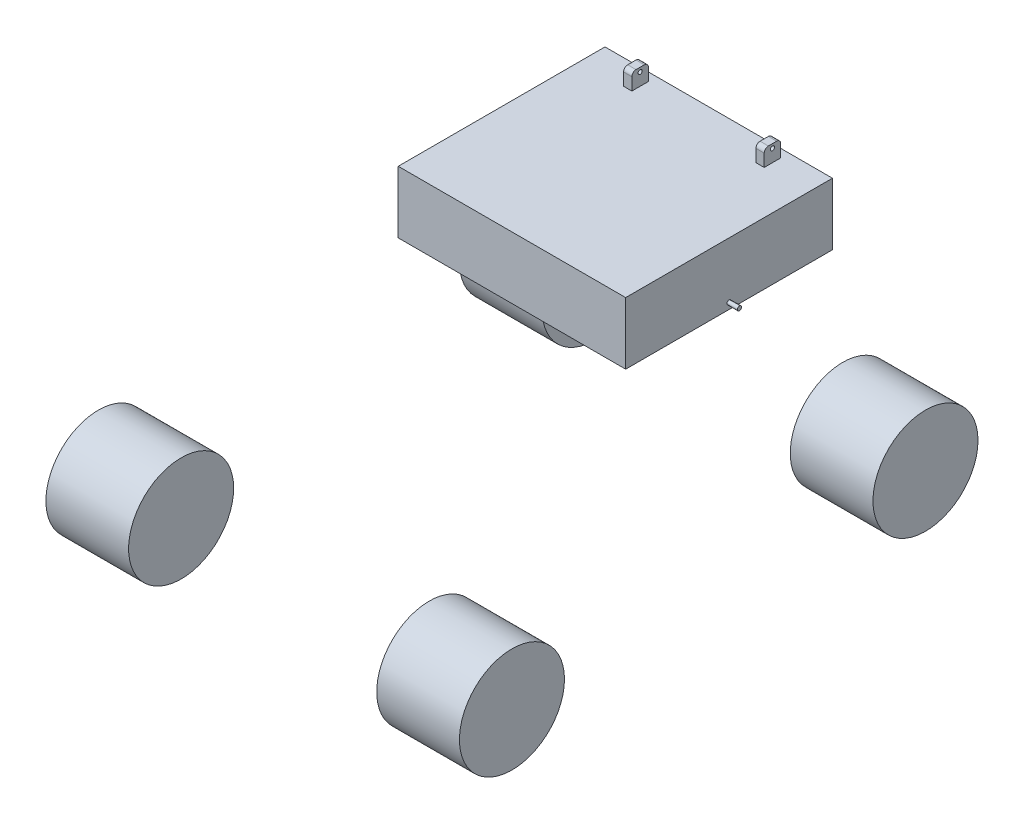
from build123d import *

# Parameters (mm, degrees)
SKETCH2_R             = 127
BOSS_EXTRUDE1_DEPTH   = 200
BOSS_EXTRUDE1_2_DEPTH = 200
SKETCH3_W             = 500
SKETCH3_H             = 150
BOSS_EXTRUDE2_DEPTH   = 275
SKETCH4_R             = 5
BOSS_EXTRUDE3_DEPTH   = 25
SKETCH6_W             = 20
SKETCH6_H             = 40
BOSS_EXTRUDE4_DEPTH   = 40
FILLET1_R             = 10
SKETCH7_R             = 5
CUT_EXTRUDE1_DEPTH    = 671


with BuildPart() as part:
    # Sketch2 → Boss-Extrude1 (new body)
    with BuildSketch(Plane(origin=(300, 0, 0), x_dir=(0, 0, -1), z_dir=(1, 0, 0))):
        with Locations((-500, 0)):
            Circle(SKETCH2_R)
    extrude(amount=BOSS_EXTRUDE1_DEPTH)


with BuildPart() as body_2:
    # Sketch2 → Boss-Extrude1 2 (new body)
    with BuildSketch(Plane(origin=(300, 0, 0), x_dir=(0, 0, -1), z_dir=(1, 0, 0))):
        with Locations((500, 0)):
            Circle(SKETCH2_R)
    extrude(amount=BOSS_EXTRUDE1_2_DEPTH)


with BuildPart() as body_3:
    # Mirror4: mirrored copy
    add(part.part.mirror(Plane(origin=(0, 0, 0), x_dir=(0, 0, 1), z_dir=(1, 0, 0))))


with BuildPart() as body_4:
    # Mirror4 2: mirrored copy
    add(body_2.part.mirror(Plane(origin=(0, 0, 0), x_dir=(0, 0, 1), z_dir=(1, 0, 0))))


with BuildPart() as body_5:
    # Sketch3 → Boss-Extrude2 (new body, symmetric)
    with BuildSketch(Plane(origin=(0, 0, 0), x_dir=(0, 0, -1), z_dir=(1, 0, 0))):
        with Locations((250, 425)):
            Rectangle(SKETCH3_W, SKETCH3_H)
    extrude(amount=BOSS_EXTRUDE2_DEPTH, both=True)

    # Sketch4 → Boss-Extrude3 (add)
    with BuildSketch(Plane(origin=(275, 0, 0), x_dir=(0, 0, -1), z_dir=(1, 0, 0))):
        with Locations((250, 365)):
            Circle(SKETCH4_R)
    boss_extrude3 = extrude(amount=BOSS_EXTRUDE3_DEPTH)

    # Mirror6: Boss-Extrude3 across plane
    add(boss_extrude3.mirror(Plane(origin=(0, 0, 0), x_dir=(0, 0, 1), z_dir=(1, 0, 0))))

    # Sketch6 → Boss-Extrude4 (add)
    with BuildSketch(Plane(origin=(0, 500, 0), x_dir=(1, 0, 0), z_dir=(0, 1, 0))):
        with Locations((-160, 460)):
            Rectangle(SKETCH6_W, SKETCH6_H)
        with Locations((160, 460)):
            Rectangle(SKETCH6_W, SKETCH6_H)
    extrude(amount=BOSS_EXTRUDE4_DEPTH)

    # Fillet1
    fillet1_edges = [body_5.edges().sort_by_distance(p)[0] for p in [
        (-160, 540, -440),
        (-160, 540, -480),
        (160, 540, -440),
        (160, 540, -480),
    ]]
    fillet(fillet1_edges, radius=FILLET1_R)

    # Sketch7 → Cut-Extrude1 (cut, through all)
    with BuildSketch(Plane(origin=(170, 0, 0), x_dir=(0, 0, -1), z_dir=(1, 0, 0))):
        with Locations((460, 530)):
            Circle(SKETCH7_R)
    extrude(amount=-CUT_EXTRUDE1_DEPTH, mode=Mode.SUBTRACT)


solid = Compound([part.part, body_2.part, body_3.part, body_4.part, body_5.part])
